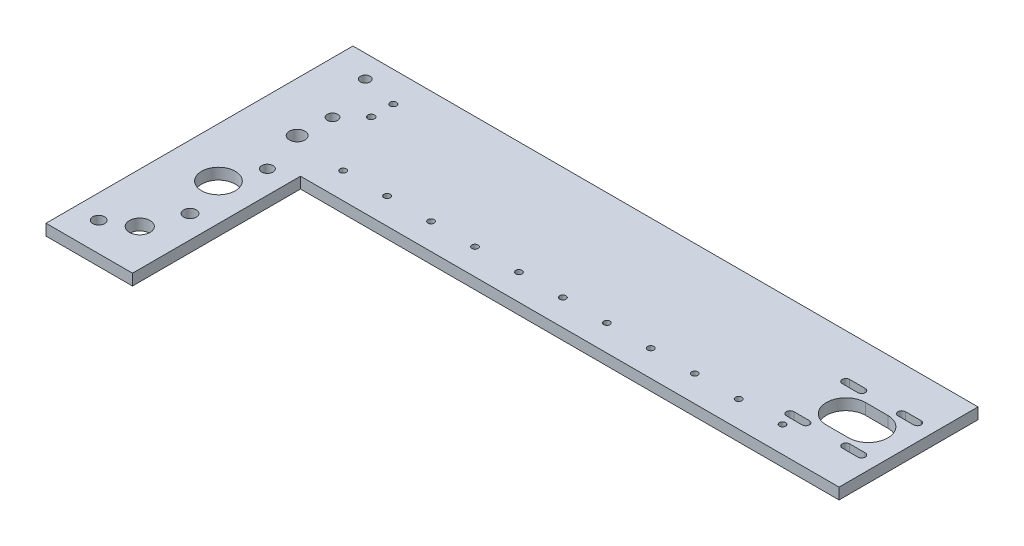
from build123d import *

# Parameters (mm, degrees)
BOSS_EXTRUDE1_DEPTH = 6.35
SKETCH2_R           = 2.979007601
CUT_EXTRUDE1_DEPTH  = 7.35
SKETCH3_R           = 4.400364859
SKETCH3_R_2         = 9.604356308
SKETCH3_R_3         = 5.866647912
SKETCH3_R_4         = 3.226485866
SKETCH3_R_5         = 3.595926688
SKETCH3_R_6         = 3.386947747
SKETCH3_R_7         = 2.817872048
SKETCH3_R_8         = 1.840203328
SKETCH3_R_9         = 1.930985623
CUT_EXTRUDE2_DEPTH  = 7.35
SKETCH4_R           = 1.778
CUT_EXTRUDE3_DEPTH  = 7.35


with BuildPart() as part:
    # Sketch1 → Boss-Extrude1 (new body)
    with BuildSketch(Plane(origin=(0, 0, 0), x_dir=(1, 0, 0), z_dir=(0, 1, 0))):
        Polygon((-177.8, -87.3125), (-177.8, 87.3125), (177.8, 87.3125), (177.8, 8.2677), (-128.5875, 8.2677), (-128.5875, -87.3125), align=None)
    extrude(amount=BOSS_EXTRUDE1_DEPTH)

    # Sketch2 → Cut-Extrude1 (cut, through all)
    with BuildSketch(Plane(origin=(0, 6.35, 0), x_dir=(1, 0, 0), z_dir=(0, 1, 0))):
        with BuildLine():
            Line((143.6116, 35.2552), (156.3116, 35.2552))
            ThreePointArc((156.3116, 35.2552), (167.4241, 46.3677), (156.3116, 57.4802))
            Line((156.3116, 57.4802), (143.6116, 57.4802))
            ThreePointArc((143.6116, 57.4802), (132.4991, 46.3677), (143.6116, 35.2552))
        make_face()
        with BuildLine():
            Line((159.4866, 60.1472), (168.376602437, 60.1472))
            ThreePointArc((168.376602437, 60.1472), (170.472102437, 62.2427), (168.376602437, 64.3382))
            Line((168.376602437, 64.3382), (159.486602437, 64.3382))
            ThreePointArc((159.486602437, 64.3382), (157.3911, 62.242701219), (159.4866, 60.1472))
        make_face()
        with BuildLine():
            ThreePointArc((159.486602437, 28.3972), (157.3911, 30.492698781), (159.4866, 32.5882))
            Line((159.4866, 32.5882), (168.376602437, 32.5882))
            ThreePointArc((168.376602437, 32.5882), (170.472102437, 30.4927), (168.376602437, 28.3972))
            Line((168.376602437, 28.3972), (159.486602437, 28.3972))
        make_face()
        with BuildLine():
            Line((127.7366, 60.1472), (136.626602437, 60.1472))
            ThreePointArc((136.626602437, 60.1472), (138.722102437, 62.2427), (136.626602437, 64.3382))
            Line((136.626602437, 64.3382), (127.736602437, 64.3382))
            ThreePointArc((127.736602437, 64.3382), (125.6411, 62.242701219), (127.7366, 60.1472))
        make_face()
        with BuildLine():
            Line((136.626602437, 28.3972), (127.736602437, 28.3972))
            ThreePointArc((127.736602437, 28.3972), (125.6411, 30.492698781), (127.7366, 32.5882))
            Line((127.7366, 32.5882), (136.626602437, 32.5882))
            ThreePointArc((136.626602437, 32.5882), (138.722102437, 30.4927), (136.626602437, 28.3972))
        make_face()
        with Locations((-148.4884, 46.3677)):
            Circle(SKETCH2_R)
    extrude(amount=-CUT_EXTRUDE1_DEPTH, mode=Mode.SUBTRACT)

    # Sketch3 → Cut-Extrude2 (cut, through all)
    with BuildSketch(Plane(origin=(0, 6.35, 0), x_dir=(1, 0, 0), z_dir=(0, 1, 0))):
        with Locations((-149.5425, 27.305)):
            Circle(SKETCH3_R)
        with Locations((-149.5425, -17.4625)):
            Circle(SKETCH3_R_2)
        with Locations((-149.5425, -62.23)):
            Circle(SKETCH3_R_3)
        with Locations((-141.63041575, 2.468910578)):
            Circle(SKETCH3_R_4)
        with Locations((-141.63041575, -41.536127476)):
            Circle(SKETCH3_R_5)
        with Locations((-164.313722824, -70.828896652)):
            Circle(SKETCH3_R_6)
        with Locations((-157.998667059, 74.512666328)):
            Circle(SKETCH3_R_7)
        with Locations((-137.701702146, 70.163316704)):
            Circle(SKETCH3_R_8)
        with Locations((-137.701702146, 57.549974441)):
            Circle(SKETCH3_R_9)
    extrude(amount=-CUT_EXTRUDE2_DEPTH, mode=Mode.SUBTRACT)

    # Sketch4 → Cut-Extrude3 (cut, through all)
    with BuildSketch(Plane(origin=(0, 6.35, 0), x_dir=(1, 0, 0), z_dir=(0, 1, 0))):
        with Locations((130.81, 23.1267)):
            Circle(SKETCH4_R)
        with Locations((105.81, 23.1267)):
            Circle(SKETCH4_R)
        with Locations((80.81, 23.1267)):
            Circle(SKETCH4_R)
        with Locations((55.81, 23.1267)):
            Circle(SKETCH4_R)
        with Locations((30.81, 23.1267)):
            Circle(SKETCH4_R)
        with Locations((5.81, 23.1267)):
            Circle(SKETCH4_R)
        with Locations((-19.19, 23.1267)):
            Circle(SKETCH4_R)
        with Locations((-44.19, 23.1267)):
            Circle(SKETCH4_R)
        with Locations((-69.19, 23.1267)):
            Circle(SKETCH4_R)
        with Locations((-94.19, 23.1267)):
            Circle(SKETCH4_R)
        with Locations((-119.19, 23.1267)):
            Circle(SKETCH4_R)
    extrude(amount=-CUT_EXTRUDE3_DEPTH, mode=Mode.SUBTRACT)


solid = part.part
